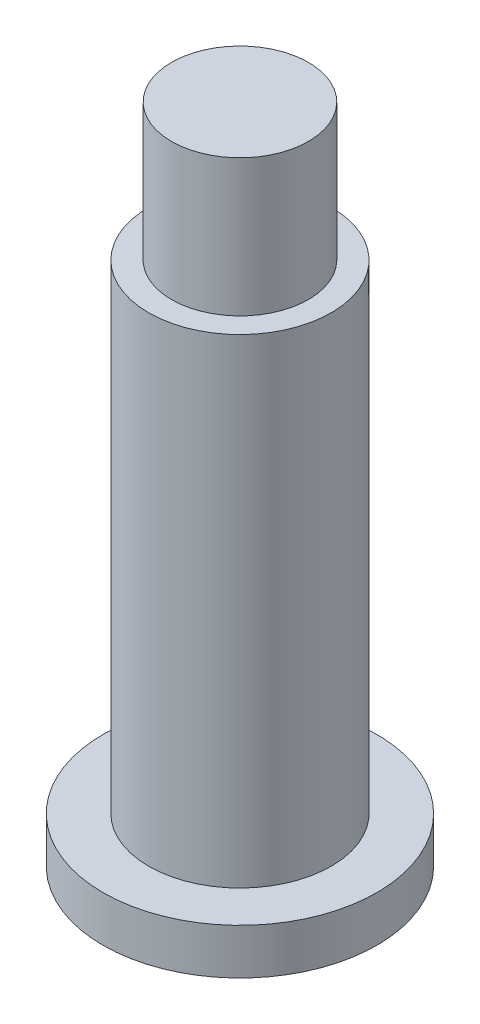
from build123d import *

# Parameters (mm, degrees)
SKETCH_1_R      = 6
EXTRUDE_1_DEPTH = 2
SKETCH_2_R      = 4
EXTRUDE_2_DEPTH = 21
SKETCH_3_R      = 3
EXTRUDE_3_DEPTH = 6


with BuildPart() as part:
    # 草图1 → 凸台-拉伸1 (new body)
    with BuildSketch(Plane(origin=(0, 0, 0), x_dir=(1, 0, 0), z_dir=(0, 1, 0))):
        Circle(SKETCH_1_R)
    extrude(amount=EXTRUDE_1_DEPTH)

    # 草图2 → 凸台-拉伸2 (add)
    with BuildSketch(Plane(origin=(0, 2, 0), x_dir=(1, 0, 0), z_dir=(0, 1, 0))):
        Circle(SKETCH_2_R)
    extrude(amount=EXTRUDE_2_DEPTH)

    # 草图3 → 凸台-拉伸3 (add)
    with BuildSketch(Plane(origin=(0, 23, 0), x_dir=(1, 0, 0), z_dir=(0, 1, 0))):
        Circle(SKETCH_3_R)
    extrude(amount=EXTRUDE_3_DEPTH)


solid = part.part
